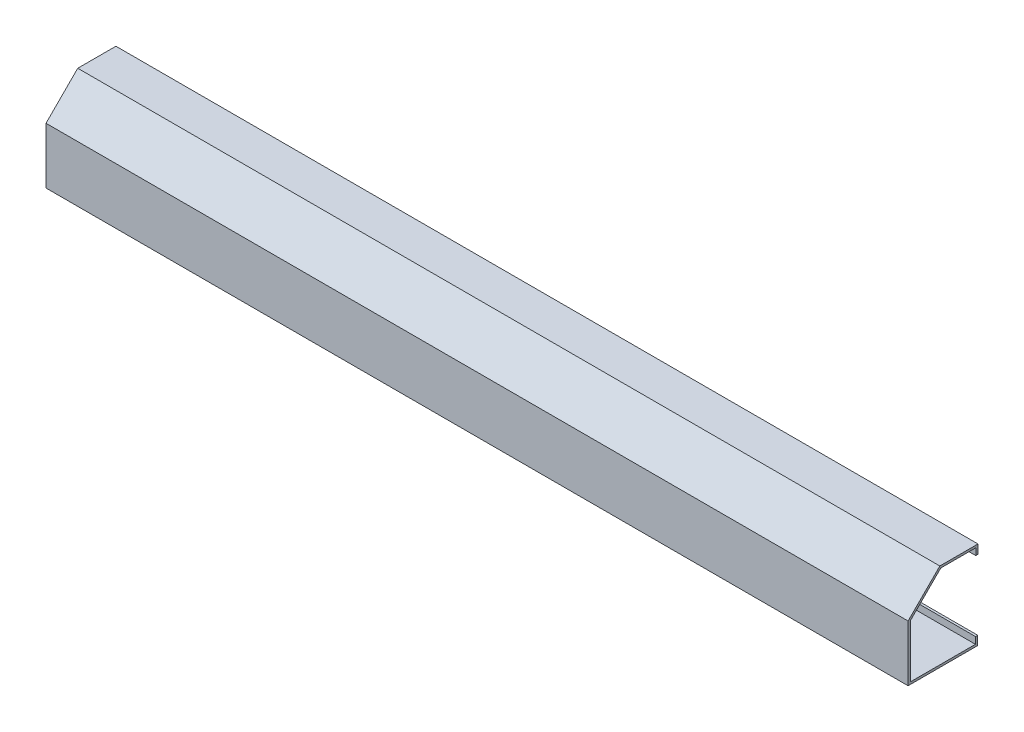
from build123d import *

# Parameters (mm, degrees)
SALIENTE_EXTRUIR1_DEPTH = 2438.4


with BuildPart() as part:
    # Croquis1 → Saliente-Extruir1 (new body)
    with BuildSketch(Plane(origin=(0, 0, 0), x_dir=(0, 0, -1), z_dir=(1, 0, 0))):
        Polygon((0, 0), (196.85, 0), (196.85, 25.4), (190.5, 25.4), (190.5, 6.35), (6.35, 6.35), (6.35, 156.119743879), (92.432817332, 242.202561211), (191.402561211, 242.202561211), (191.402561211, 223.152561211), (197.752561211, 223.152561211), (197.752561211, 248.552561211), (89.802561211, 248.552561211), (0, 158.75), align=None)
    extrude(amount=SALIENTE_EXTRUIR1_DEPTH)


solid = part.part
